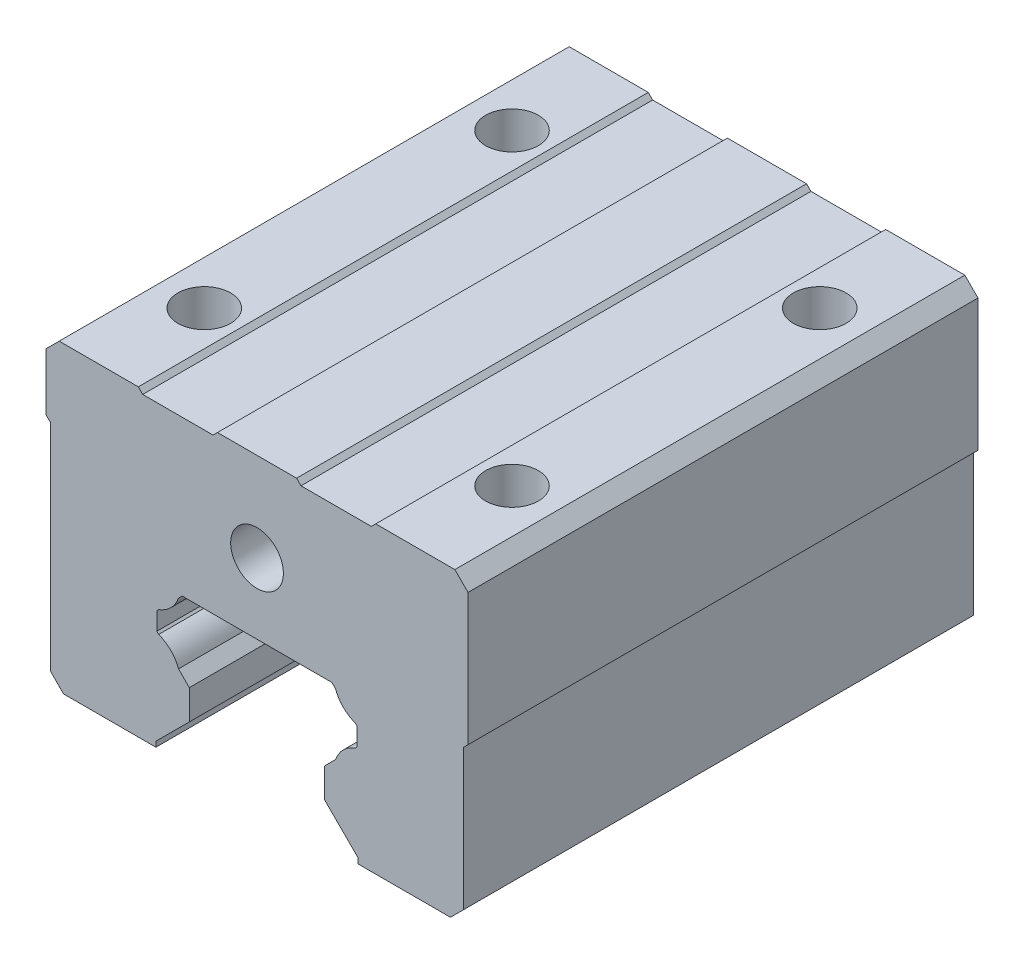
from build123d import *

# Parameters (mm, degrees)
BLOCK_DEPTH                     = 29
TAP_DRILL_FOR_M8X1_0_TAP1_D     = 6
TAP_DRILL_FOR_M8X1_0_TAP1_DEPTH = 12.5
TAP_DRILL_FOR_M8X1_0_TAP1_TIP   = 1.561701152
F_6_0_6_DIAMETER_HOLE1_D        = 6


with BuildPart() as part:
    # Sketch2 → Block (new body, symmetric)
    with BuildSketch(Plane.XY):
        with BuildLine():
            Line((22, 0), (23.5, 1.5))
            Line((23.5, 1.5), (23.5, 17.499972901))
            Line((23.5, 17.499972901), (24, 17.999972901))
            Line((24, 17.999972901), (24, 32.999972901))
            Line((24, 32.999972901), (22.5, 34.5))
            Line((22.5, 34.5), (13.5, 34.5))
            Line((13.5, 34.5), (13.000005928, 34))
            Line((13.000005928, 34), (5.000005928, 34))
            Line((5.000005928, 34), (4.500011856, 34.5))
            Line((4.500011856, 34.5), (-4.499988144, 34.5))
            Line((-4.499988144, 34.5), (-4.999982216, 34))
            Line((-4.999982216, 34), (-12.999982216, 34))
            Line((-12.999982216, 34), (-13.499976288, 34.5))
            Line((-13.499976288, 34.5), (-22.499976288, 34.5))
            Line((-22.499976288, 34.5), (-24, 32.999996612))
            Line((-24, 32.999996612), (-24, 26.499996612))
            Line((-24, 26.499996612), (-23.5, 25.999996612))
            Line((-23.5, 25.999996612), (-23.5, 1.5))
            Line((-23.5, 1.5), (-22, 0))
            Line((-22, 0), (-11.5, 0))
            Line((-11.5, 0), (-11.5, 0.6))
            Line((-11.5, 0.6), (-7.7, 4.393650985))
            Line((-7.7, 4.393650985), (-7.7, 7.773650985))
            Line((-7.7, 7.773650985), (-8.93, 9.0057095))
            ThreePointArc((-8.93, 9.0057095), (-9.805517545, 10.387881926), (-11.186224007, 11.2657095))
            Line((-11.186224007, 11.2657095), (-11.39587314, 11.4757095))
            Line((-11.39587314, 11.4757095), (-11.39587314, 13.5057095))
            Line((-11.39587314, 13.5057095), (-11.186224007, 13.7157095))
            ThreePointArc((-11.186224007, 13.7157095), (-9.805517545, 14.593537075), (-8.93, 15.9757095))
            Line((-8.93, 15.9757095), (-8.520685025, 16.3857095))
            Line((-8.520685025, 16.3857095), (8.520685025, 16.3857095))
            Line((8.520685025, 16.3857095), (8.93, 15.9757095))
            ThreePointArc((8.93, 15.9757095), (9.805517545, 14.593537075), (11.186224007, 13.7157095))
            Line((11.186224007, 13.7157095), (11.39587314, 13.5057095))
            Line((11.39587314, 13.5057095), (11.39587314, 11.4757095))
            Line((11.39587314, 11.4757095), (11.186224007, 11.2657095))
            ThreePointArc((11.186224007, 11.2657095), (9.805517545, 10.387881926), (8.93, 9.0057095))
            Line((8.93, 9.0057095), (7.7, 7.773650985))
            Line((7.7, 7.773650985), (7.7, 4.393650985))
            Line((7.7, 4.393650985), (11.5, 0.6))
            Line((11.5, 0.6), (11.5, 0))
            Line((11.5, 0), (22, 0))
        make_face()
    extrude(amount=BLOCK_DEPTH, both=True)

    # Tap Drill for M8x1.0 Tap1
    with Locations(Plane(origin=(0, 34.5, 0), x_dir=(1, 0, 0), z_dir=(0, 1, 0))):
        with Locations((17.5, 17.5), (-17.5, 17.5), (17.5, -17.5), (-17.5, -17.5)):
            Hole(TAP_DRILL_FOR_M8X1_0_TAP1_D / 2, depth=TAP_DRILL_FOR_M8X1_0_TAP1_DEPTH)
            with Locations((0, 0, -(TAP_DRILL_FOR_M8X1_0_TAP1_DEPTH + TAP_DRILL_FOR_M8X1_0_TAP1_TIP / 2))):  # 125° drill point
                Cone(0, TAP_DRILL_FOR_M8X1_0_TAP1_D / 2, TAP_DRILL_FOR_M8X1_0_TAP1_TIP, mode=Mode.SUBTRACT)

    # Ø6.0 (6) Diameter Hole1 (through all)
    with Locations(Plane(origin=(0, 0, -29), x_dir=(-1, 0, 0), z_dir=(0, 0, -1))):
        with Locations((0, 24.3857095)):
            Hole(F_6_0_6_DIAMETER_HOLE1_D / 2)


solid = part.part
